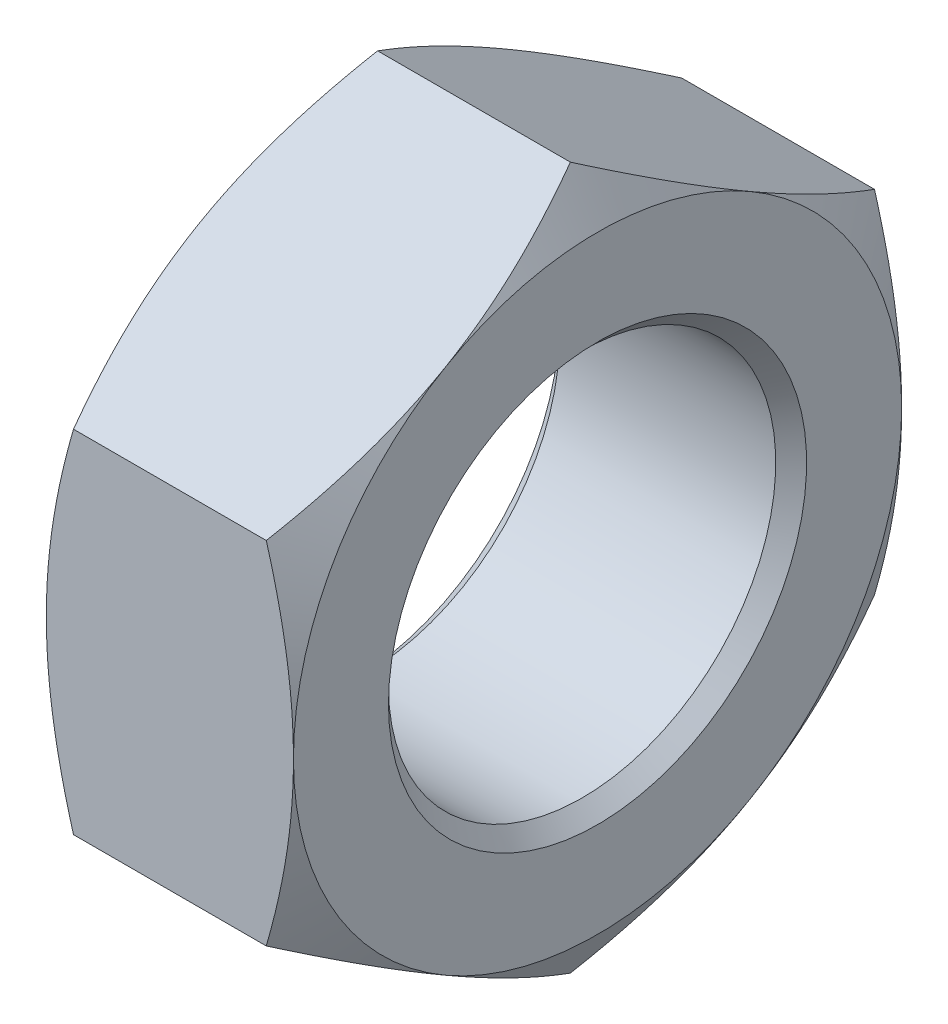
from build123d import *

# Parameters (mm, degrees)
SKETCH_2_W          = 64
SKETCH_2_H          = 64
CUT_EXTRUDE_1_DEPTH = 26


with BuildPart() as part:
    # 草图1 → 旋转1 (revolve)
    with BuildSketch(Plane.XY):
        Polygon((0, 0), (0, 16), (1.847520861, 19.2), (11.152479139, 19.2), (13, 16), (13, 0), align=None)
    revolve(axis=Axis((13, 0, 0), (-1, 0, 0)))

    # 草图2 → 切除-拉伸1 (cut)
    with BuildSketch(Plane(origin=(0, 0, 0), x_dir=(0, 0, -1), z_dir=(1, 0, 0))):
        Rectangle(SKETCH_2_W, SKETCH_2_H)
        Polygon((-16, -9.237604307), (0, -18.475208614), (16, -9.237604307), (16, 9.237604307), (0, 18.475208614), (-16, 9.237604307), align=None, mode=Mode.SUBTRACT)
    extrude(amount=CUT_EXTRUDE_1_DEPTH, mode=Mode.SUBTRACT)

    # 草图3 → 切除-旋转1 (revolve, cut)
    with BuildSketch(Plane.XY):
        Polygon((0, 0), (0, 11), (0.812, 10.188), (12.188, 10.188), (13, 11), (13, 0), align=None)
    revolve(axis=Axis((13, 0, 0), (-1, 0, 0)), mode=Mode.SUBTRACT)


solid = part.part
